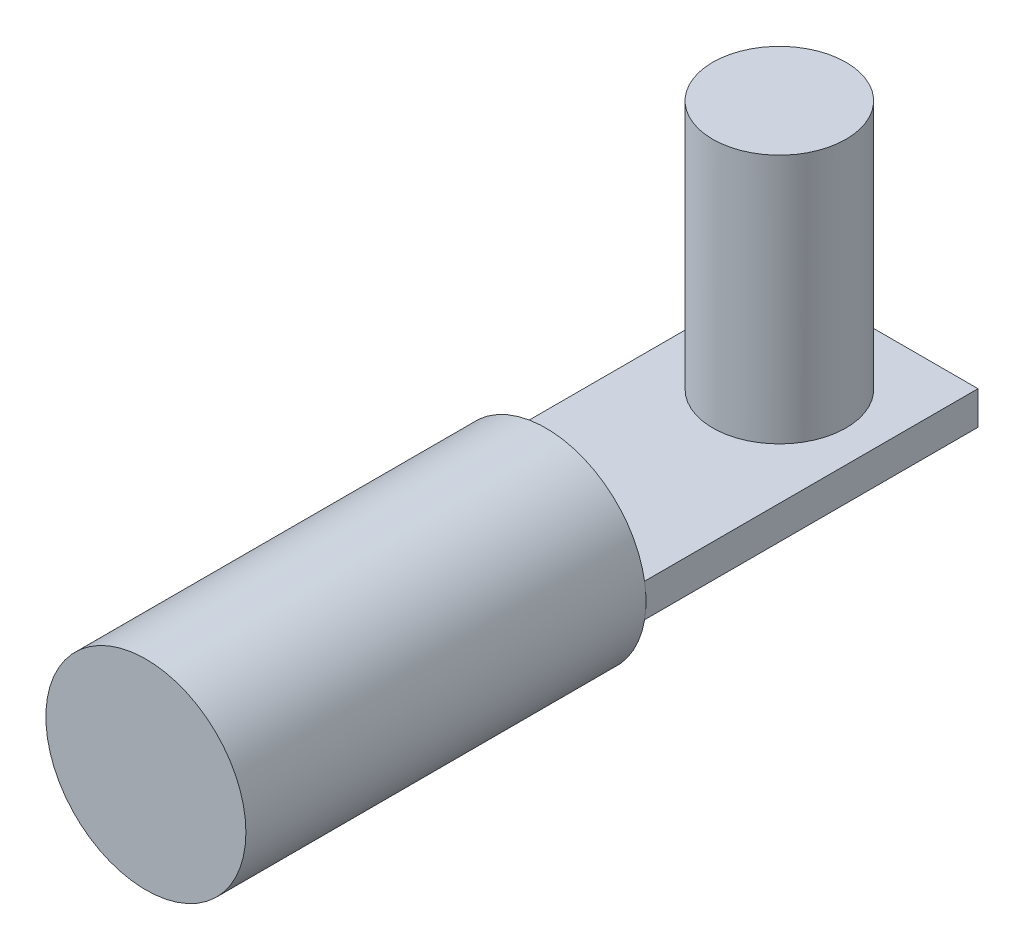
from build123d import *

# Parameters (mm, degrees)
SKETCH1_R           = 3
BOSS_EXTRUDE1_DEPTH = 12
SKETCH2_W           = 5.91565448
SKETCH2_H           = 1.002512874
BOSS_EXTRUDE2_DEPTH = 10
SKETCH4_R           = 2
BOSS_EXTRUDE3_DEPTH = 7.5


with BuildPart() as part:
    # Sketch1 → Boss-Extrude1 (new body)
    with BuildSketch(Plane.XY):
        Circle(SKETCH1_R)
    extrude(amount=BOSS_EXTRUDE1_DEPTH)

    # Sketch2 → Boss-Extrude2 (add)
    with BuildSketch(Plane(origin=(0, 0, 0), x_dir=(-1, 0, 0), z_dir=(0, 0, -1))):
        Rectangle(SKETCH2_W, SKETCH2_H)
    extrude(amount=BOSS_EXTRUDE2_DEPTH)

    # Sketch4 → Boss-Extrude3 (add)
    with BuildSketch(Plane(origin=(0, 0.501256437, 0), x_dir=(1, 0, 0), z_dir=(0, 1, 0))):
        with Locations((0, 7)):
            Circle(SKETCH4_R)
    extrude(amount=BOSS_EXTRUDE3_DEPTH)


solid = part.part
